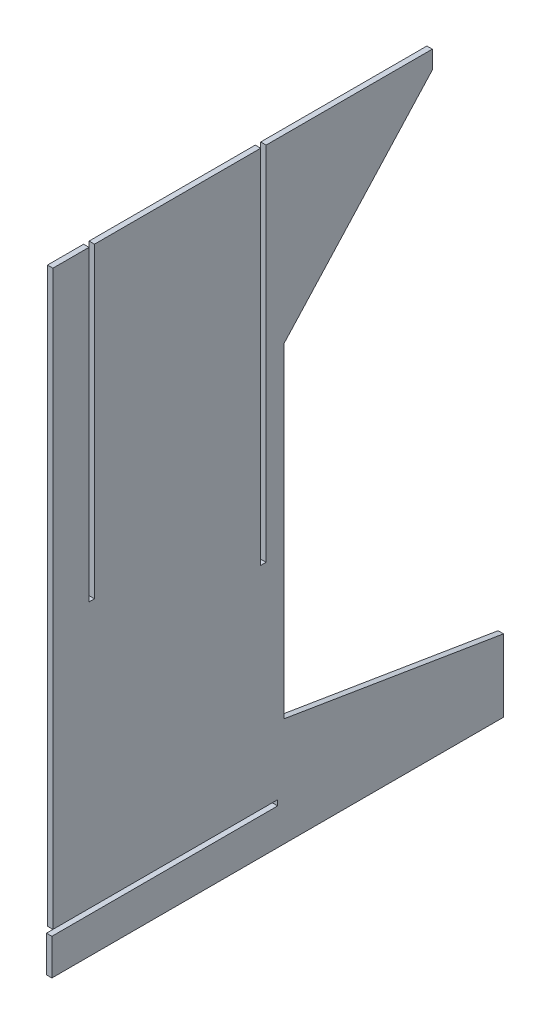
from build123d import *

# Parameters (mm, degrees)
BOSS_EXTRUDE1_DEPTH = 3


with BuildPart() as part:
    # Sketch1 → Boss-Extrude1 (new body)
    with BuildSketch(Plane(origin=(0, 0, 0), x_dir=(0, 0, -1), z_dir=(1, 0, 0))):
        Polygon((3.569703573, -49.903540618), (3.569703573, -229.903540618), (125, -249.903540618), (125, -289.903540618), (-125, -289.903540618), (-125, -269.903540618), (0, -269.903540618), (0, -266.903540618), (-124.430296427, -266.903540618), (-124.430296427, 50.095982084), (-104.430296427, 50.095982084), (-104.430296427, -119.904017916), (-101.430296427, -119.904017916), (-101.430296427, 50.095982084), (-9.430296427, 50.095982084), (-9.430296427, -149.903540618), (-6.430296427, -149.903540618), (-6.430296427, 50.095982084), (85.569703573, 50.095982084), (85.569703573, 40.095982084), align=None)
    extrude(amount=BOSS_EXTRUDE1_DEPTH)


solid = part.part
